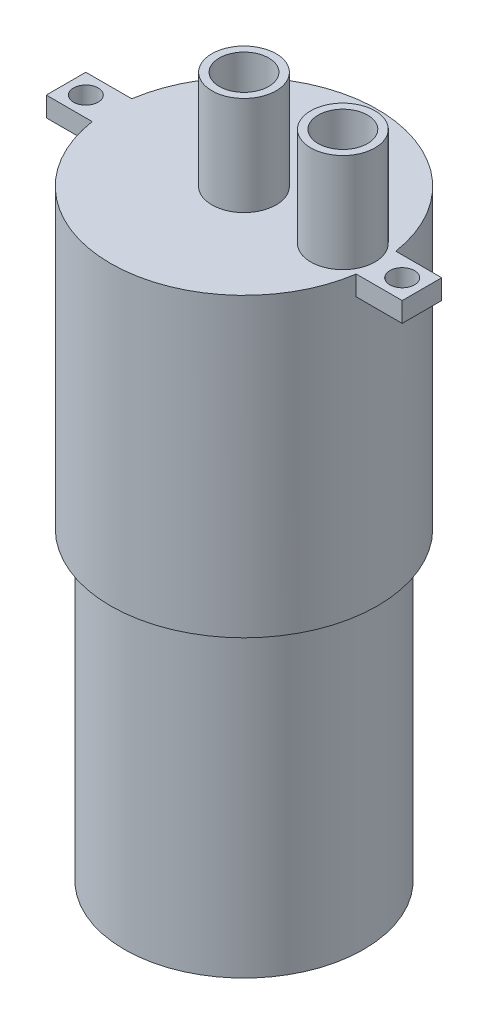
from build123d import *

# Parameters (mm, degrees)
SKIZZE2_R                       = 3.25
SKIZZE2_R_2                     = 2.5
AUFSATZ_LINEAR_AUSTRAGEN1_DEPTH = 10
SKIZZE3_R                       = 1.25
AUFSATZ_LINEAR_AUSTRAGEN2_DEPTH = 2


with BuildPart() as part:
    # Skizze1 → Rotation1 (revolve)
    with BuildSketch(Plane.XY):
        Polygon((0, 0), (12.1, 0), (12.1, 30.8), (13.5, 30.8), (13.5, 60.8), (3.25, 60.8), (3.25, 70.8), (2.5, 70.8), (2.5, 62.8), (0, 62.8), align=None)
    revolve(axis=Axis((0, 12.380405046, 0), (0, -1, 0)))

    # Skizze2 → Aufsatz-Linear austragen1 (add)
    with BuildSketch(Plane(origin=(0, 60.8, 0), x_dir=(1, 0, 0), z_dir=(0, 1, 0))):
        with Locations((10, 0)):
            Circle(SKIZZE2_R)
        with Locations((10, 0)):
            Circle(SKIZZE2_R_2, mode=Mode.SUBTRACT)
    extrude(amount=AUFSATZ_LINEAR_AUSTRAGEN1_DEPTH)

    # Skizze3 → Aufsatz-Linear austragen2 (add)
    with BuildSketch(Plane(origin=(0, 60.8, 0), x_dir=(1, 0, 0), z_dir=(0, 1, 0))):
        with BuildLine():
            Line((-13.351029923, 2), (-18, 2))
            Line((-18, 2), (-18, -2))
            Line((-18, -2), (-13.351029923, -2))
            ThreePointArc((-13.351029923, -2), (-13.5, 0), (-13.351029923, 2))
        make_face()
        with Locations((-16, 0)):
            Circle(SKIZZE3_R, mode=Mode.SUBTRACT)
        with BuildLine():
            Line((18, -2), (13.351029923, -2))
            ThreePointArc((13.351029923, -2), (13.5, 0), (13.351029923, 2))
            Line((13.351029923, 2), (18, 2))
            Line((18, 2), (18, -2))
        make_face()
        with Locations((16, 0)):
            Circle(SKIZZE3_R, mode=Mode.SUBTRACT)
    extrude(amount=-AUFSATZ_LINEAR_AUSTRAGEN2_DEPTH)


solid = part.part
